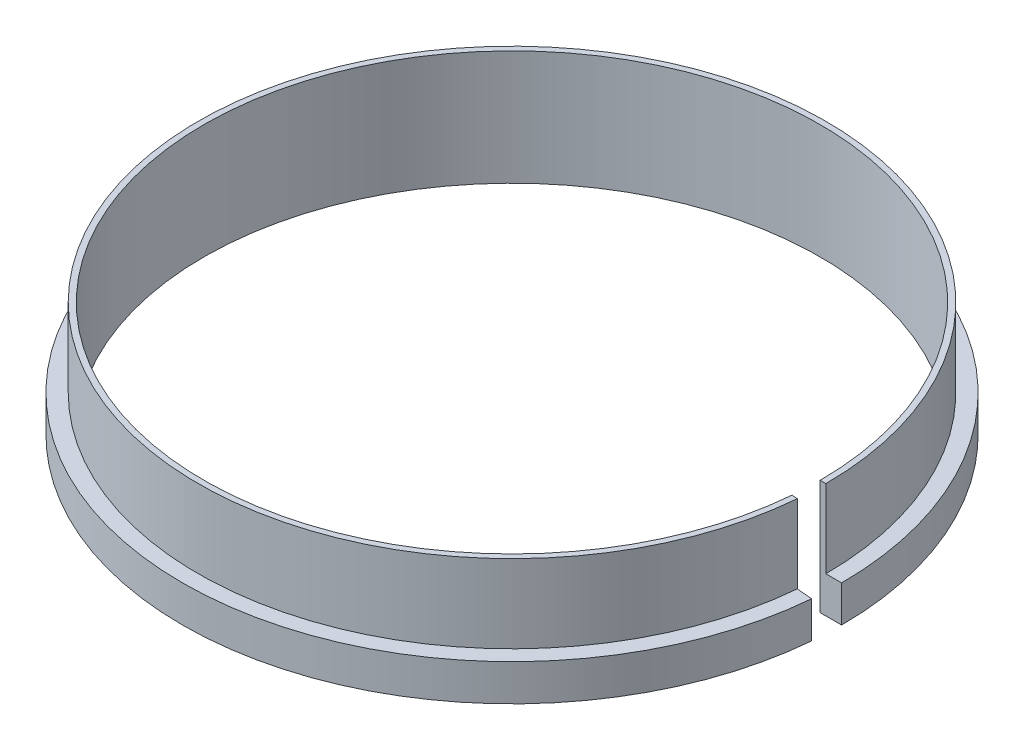
from build123d import *

# Parameters (mm, degrees)
REVOLVE1_ANGLE = 355


with BuildPart() as part:
    # Sketch1 → Revolve1 (revolve)
    with BuildSketch(Plane.XY):
        Polygon((21.5, 0), (21.5, 8), (21.9, 8), (21.9, 2.55), (23, 2.55), (23, 0), align=None)
    revolve(axis=Axis((0, 0, 0), (0, 1, 0)), revolution_arc=REVOLVE1_ANGLE)


solid = part.part
